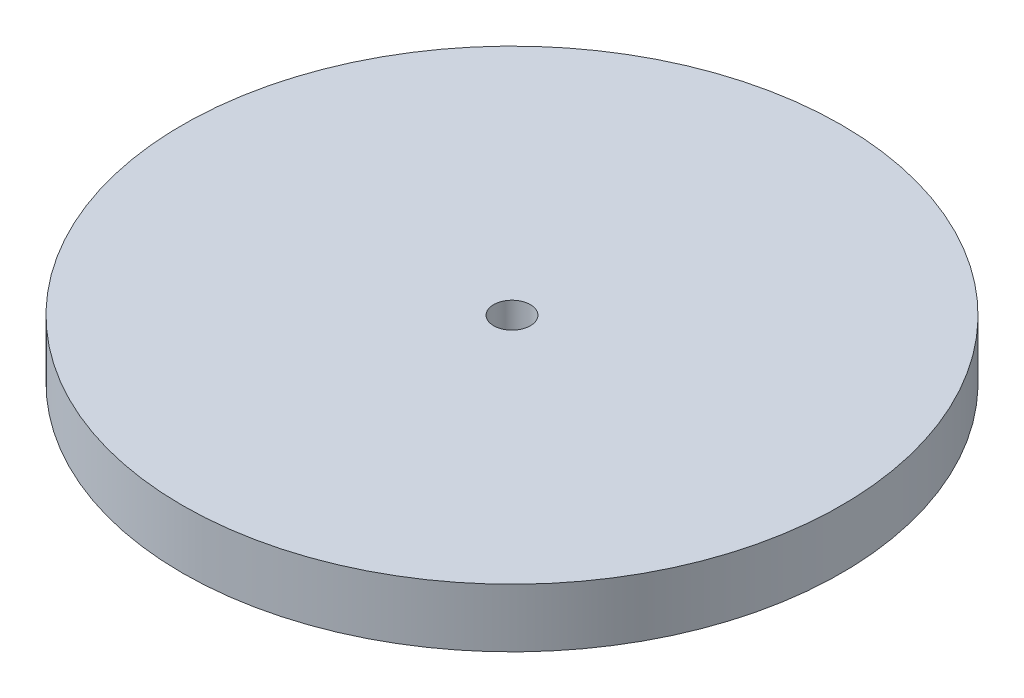
from build123d import *

# Parameters (mm, degrees)
SKETCH1_R           = 18
BOSS_EXTRUDE1_DEPTH = 3.2
SKETCH2_R           = 1.0025
CUT_EXTRUDE1_DEPTH  = 4.2


with BuildPart() as part:
    # Sketch1 → Boss-Extrude1 (new body)
    with BuildSketch(Plane(origin=(0, 0, 0), x_dir=(1, 0, 0), z_dir=(0, 1, 0))):
        Circle(SKETCH1_R)
    extrude(amount=BOSS_EXTRUDE1_DEPTH)

    # Sketch2 → Cut-Extrude1 (cut, through all)
    with BuildSketch(Plane(origin=(0, 3.2, 0), x_dir=(1, 0, 0), z_dir=(0, 1, 0))):
        Circle(SKETCH2_R)
    extrude(amount=-CUT_EXTRUDE1_DEPTH, mode=Mode.SUBTRACT)


solid = part.part
